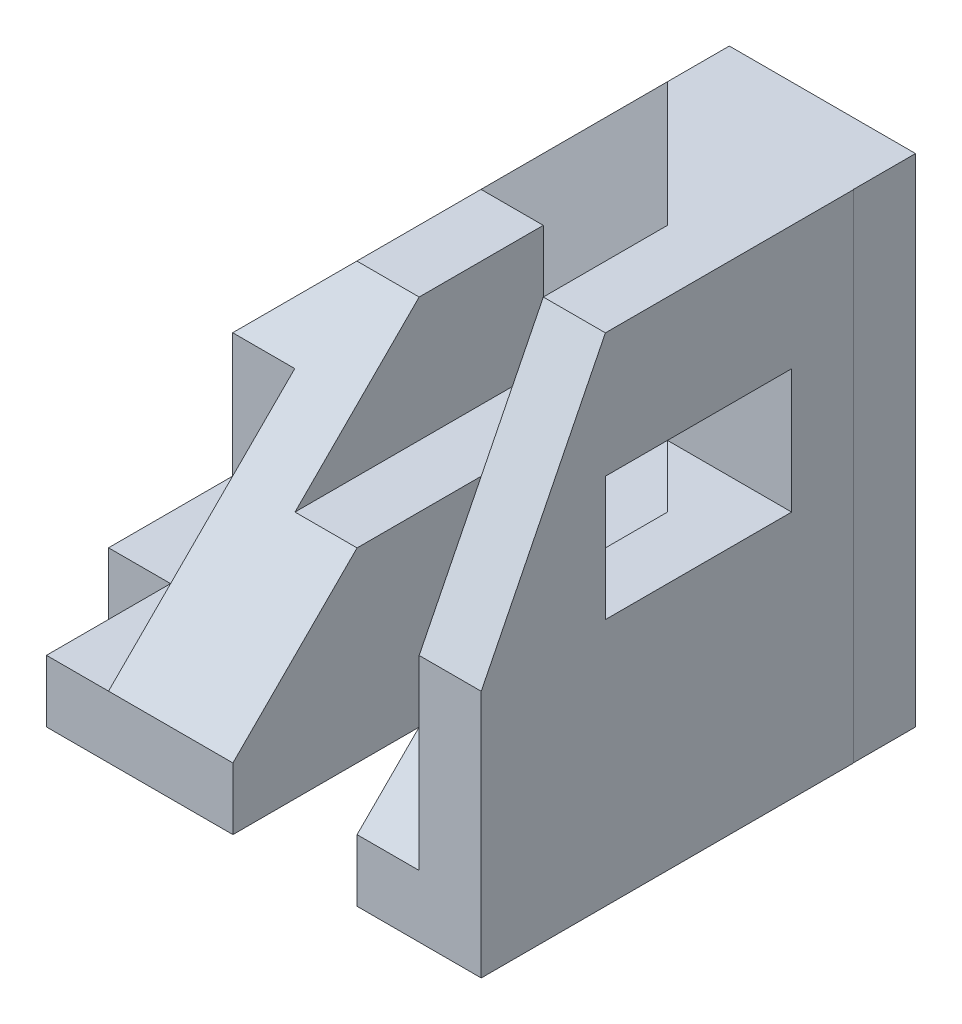
from build123d import *

# Parameters (mm, degrees)
BOSS_EXTRUDE1_DEPTH = 1
BOSS_EXTRUDE2_DEPTH = 6
CUT_EXTRUDE1_DEPTH  = 4
CUT_EXTRUDE2_DEPTH  = 4
SKETCH6_W           = 1
SKETCH6_H           = 2
CUT_EXTRUDE3_DEPTH  = 4
BOSS_EXTRUDE3_DEPTH = 4
SKETCH8_W           = 2
SKETCH8_H           = 4
CUT_EXTRUDE4_DEPTH  = 4
BOSS_EXTRUDE4_DEPTH = 1
SKETCH14_W          = 4.502969787
SKETCH14_H          = 1
CUT_EXTRUDE6_DEPTH  = 4
SKETCH11_W          = 3
SKETCH11_H          = 2
CUT_EXTRUDE5_DEPTH  = 2
BOSS_EXTRUDE5_DEPTH = 5
SKETCH16_W          = 1
SKETCH16_H          = 2
CUT_EXTRUDE7_DEPTH  = 3


with BuildPart() as part:
    # Sketch2 → Boss-Extrude1 (new body)
    with BuildSketch(Plane.XY):
        Polygon((0, 0), (0, 3), (5, 8), (8, 8), (8, 0), align=None)
    extrude(amount=BOSS_EXTRUDE1_DEPTH)

    # Sketch3 → Boss-Extrude2 (add)
    with BuildSketch(Plane.XY.offset(1)):
        Polygon((0, 0), (0, 3), (2, 5), (3.00380266, 5), (3.00380266, 3), (3.00380266, 0), align=None)
    extrude(amount=BOSS_EXTRUDE2_DEPTH)

    # Sketch4 → Cut-Extrude1 (cut)
    with BuildSketch(Plane.ZY):
        Polygon((3, 5), (7, 1), (7, 5), align=None)
    extrude(amount=-CUT_EXTRUDE1_DEPTH, mode=Mode.SUBTRACT)

    # Sketch5 → Cut-Extrude2 (cut)
    with BuildSketch(Plane(origin=(0, 5, 0), x_dir=(1, 0, 0), z_dir=(0, 1, 0))):
        Polygon((1, -4), (1, -3), (0, -3), (0, -3.75), (0, -7), (2, -7), (2, -4), align=None)
    extrude(amount=-CUT_EXTRUDE2_DEPTH, mode=Mode.SUBTRACT)

    # Sketch6 → Cut-Extrude3 (cut)
    with BuildSketch(Plane(origin=(0, 1, 0), x_dir=(1, 0, 0), z_dir=(0, 1, 0))):
        with Locations((0.5, -6)):
            Rectangle(SKETCH6_W, SKETCH6_H)
    extrude(amount=-CUT_EXTRUDE3_DEPTH, mode=Mode.SUBTRACT)

    # Sketch7 → Boss-Extrude3 (add)
    with BuildSketch(Plane(origin=(3.00380266, 0, 0), x_dir=(0, 0, -1), z_dir=(1, 0, 0))):
        Polygon((-7, 0), (-7, 1), (-4, 4), (-1, 4), (-1, 0), align=None)
    extrude(amount=BOSS_EXTRUDE3_DEPTH)

    # Sketch8 → Cut-Extrude4 (cut)
    with BuildSketch(Plane(origin=(0, 4, 0), x_dir=(1, 0, 0), z_dir=(0, 1, 0))):
        with Locations((5.00380266, -5)):
            Rectangle(SKETCH8_W, SKETCH8_H)
    extrude(amount=-CUT_EXTRUDE4_DEPTH, mode=Mode.SUBTRACT)

    # Sketch9 → Boss-Extrude4 (add)
    with BuildSketch(Plane(origin=(7.00380266, 0, 0), x_dir=(0, 0, -1), z_dir=(1, 0, 0))):
        Polygon((-7, 0), (-1, 0), (-1, 8), (-5, 8), (-7, 4), align=None)
    extrude(amount=BOSS_EXTRUDE4_DEPTH)

    # Sketch14 → Cut-Extrude6 (cut)
    with BuildSketch(Plane(origin=(3.00380266, 0, 0), x_dir=(0, 0, -1), z_dir=(1, 0, 0))):
        with Locations((-3.251484894, 3.5)):
            Rectangle(SKETCH14_W, SKETCH14_H)
    extrude(amount=CUT_EXTRUDE6_DEPTH, mode=Mode.SUBTRACT)

    # Sketch11 → Cut-Extrude5 (cut)
    with BuildSketch(Plane(origin=(8.00380266, 0, 0), x_dir=(0, 0, -1), z_dir=(1, 0, 0))):
        with Locations((-3.5, 5)):
            Rectangle(SKETCH11_W, SKETCH11_H)
    extrude(amount=-CUT_EXTRUDE5_DEPTH, mode=Mode.SUBTRACT)

    # Sketch15 → Boss-Extrude5 (add)
    with BuildSketch(Plane(origin=(0, 3, 0), x_dir=(1, 0, 0), z_dir=(0, 1, 0))):
        Polygon((7.00380266, -3), (5.00380266, -1), (7.00380266, -1), align=None)
    extrude(amount=BOSS_EXTRUDE5_DEPTH)

    # Sketch16 → Cut-Extrude7 (cut)
    with BuildSketch(Plane(origin=(7.00380266, 0, 0), x_dir=(0, 0, -1), z_dir=(1, 0, 0))):
        with Locations((-2.5, 5)):
            Rectangle(SKETCH16_W, SKETCH16_H)
    extrude(amount=-CUT_EXTRUDE7_DEPTH, mode=Mode.SUBTRACT)


solid = part.part
